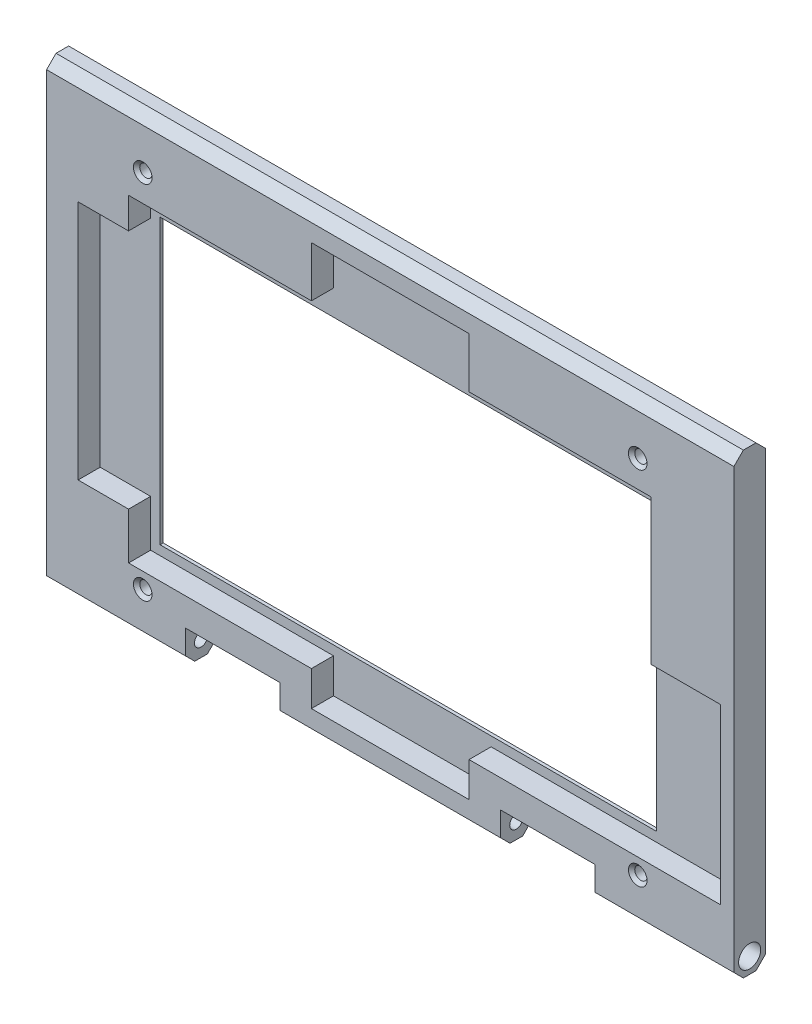
from build123d import *

# Parameters (mm, degrees)
CROQUIS1_W              = 218
CROQUIS1_H              = 145
SALIENTE_EXTRUIR1_DEPTH = 10
CORTAR_EXTRUIR1_DEPTH   = 7
CROQUIS3_W              = 157.5
CROQUIS3_H              = 90
CORTAR_EXTRUIR2_DEPTH   = 4
CHAFL_N1_SIZE           = 2
CORTAR_EXTRUIR3_START   = -2
CROQUIS4_R              = 1.95
CORTAR_EXTRUIR3_DEPTH   = 9
CROQUIS5_W              = 22
CROQUIS5_H              = 55
CROQUIS5_W_2            = 16
CROQUIS5_H_2            = 76.408682756
CROQUIS5_W_3            = 50
CROQUIS5_H_3            = 16
CORTAR_EXTRUIR4_DEPTH   = 7
CROQUIS8_R              = 2.1
CORTAR_EXTRUIR6_DEPTH   = 219
CROQUIS9_R              = 3.5
CORTAR_EXTRUIR7_DEPTH   = 6
CHAFL_N2_SIZE           = 3
CROQUIS10_W             = 30
CROQUIS10_H             = 10.660254038
CORTAR_EXTRUIR8_DEPTH   = 11
CHAFL_N3_SIZE           = 1


with BuildPart() as part:
    # Croquis1 → Saliente-Extruir1 (new body)
    with BuildSketch(Plane.XY):
        Rectangle(CROQUIS1_W, CROQUIS1_H)
    extrude(amount=SALIENTE_EXTRUIR1_DEPTH)

    # Croquis2 → Cortar-Extruir1 (cut)
    with BuildSketch(Plane.XY.offset(10)):
        Polygon((-83, 43), (-83, 48), (82.7, 48), (82.7, -53), (80.5, -53), (-83, -53), align=None)
    extrude(amount=-CORTAR_EXTRUIR1_DEPTH, mode=Mode.SUBTRACT)

    # Croquis3 → Cortar-Extruir2 (cut, through all)
    with BuildSketch(Plane.XY.offset(3)):
        with Locations((-1.25, -5)):
            Rectangle(CROQUIS3_W, CROQUIS3_H)
    extrude(amount=-CORTAR_EXTRUIR2_DEPTH, mode=Mode.SUBTRACT)

    # Chafl_n1
    chafl_n1_edges = [part.edges().sort_by_distance(p)[0] for p in [
        (-80, -5, 0),
        (-1.25, 40, 0),
        (77.5, -5, 0),
        (-1.25, -50, 0),
    ]]
    chamfer(chafl_n1_edges, length=CHAFL_N1_SIZE)

    # Croquis4 → Cortar-Extruir3 (cut, through all)
    with BuildSketch(Plane(origin=(0, 0, 0), x_dir=(-1, 0, 0), z_dir=(0, 0, -1)).offset(CORTAR_EXTRUIR3_START)):
        with Locations((-78.5, 56.5)):
            Circle(CROQUIS4_R)
        with Locations((78.5, 56.5)):
            Circle(CROQUIS4_R)
        with Locations((78.5, -58)):
            Circle(CROQUIS4_R)
        with Locations((-78.5, -58)):
            Circle(CROQUIS4_R)
    extrude(amount=-CORTAR_EXTRUIR3_DEPTH, mode=Mode.SUBTRACT)

    # Croquis5 → Cortar-Extruir4 (cut)
    with BuildSketch(Plane.XY.offset(10)):
        with Locations((93.7, -25.5)):
            Rectangle(CROQUIS5_W, CROQUIS5_H)
        with Locations((-91, 0)):
            Rectangle(CROQUIS5_W_2, CROQUIS5_H_2)
        with Locations((0, 56)):
            Rectangle(CROQUIS5_W_3, CROQUIS5_H_3)
        with Locations((0, -56)):
            Rectangle(CROQUIS5_W_3, CROQUIS5_H_3)
    extrude(amount=-CORTAR_EXTRUIR4_DEPTH, mode=Mode.SUBTRACT)

    # Croquis8 → Cortar-Extruir6 (cut, through all)
    with BuildSketch(Plane.ZY.offset(109)):
        with Locations((5, -67.5)):
            Circle(CROQUIS8_R)
    extrude(amount=-CORTAR_EXTRUIR6_DEPTH, mode=Mode.SUBTRACT)

    # Croquis9 → Cortar-Extruir7 (cut)
    with BuildSketch(Plane.ZY.offset(109)):
        with Locations((5, -67.5)):
            Circle(CROQUIS9_R)
    cortar_extruir7 = extrude(amount=-CORTAR_EXTRUIR7_DEPTH, mode=Mode.SUBTRACT)

    # Simetr_a1: Cortar-Extruir7 across plane
    add(cortar_extruir7.mirror(Plane(origin=(0, 0, 0), x_dir=(0, 0, 1), z_dir=(1, 0, 0))), mode=Mode.SUBTRACT)

    # Chafl_n2
    chafl_n2_edges = [part.edges().sort_by_distance(p)[0] for p in [
        (0, 72.5, 10),
        (0, 72.5, 0),
        (0, -72.5, 0),
        (0, -72.5, 10),
    ]]
    chamfer(chafl_n2_edges, length=CHAFL_N2_SIZE)

    # Croquis10 → Cortar-Extruir8 (cut, through all)
    with BuildSketch(Plane(origin=(0, 0, 0), x_dir=(-1, 0, 0), z_dir=(0, 0, -1))):
        with Locations((-50, -67.169872981)):
            Rectangle(CROQUIS10_W, CROQUIS10_H)
        with Locations((50, -67.169872981)):
            Rectangle(CROQUIS10_W, CROQUIS10_H)
    extrude(amount=-CORTAR_EXTRUIR8_DEPTH, mode=Mode.SUBTRACT)

    # Chafl_n3
    chafl_n3_edges = [part.edges().sort_by_distance(p)[0] for p in [
        (80.45, -58, 10),
        (-76.55, -58, 10),
        (-76.55, 56.5, 10),
        (80.45, 56.5, 10),
    ]]
    chamfer(chafl_n3_edges, length=CHAFL_N3_SIZE)


solid = part.part
